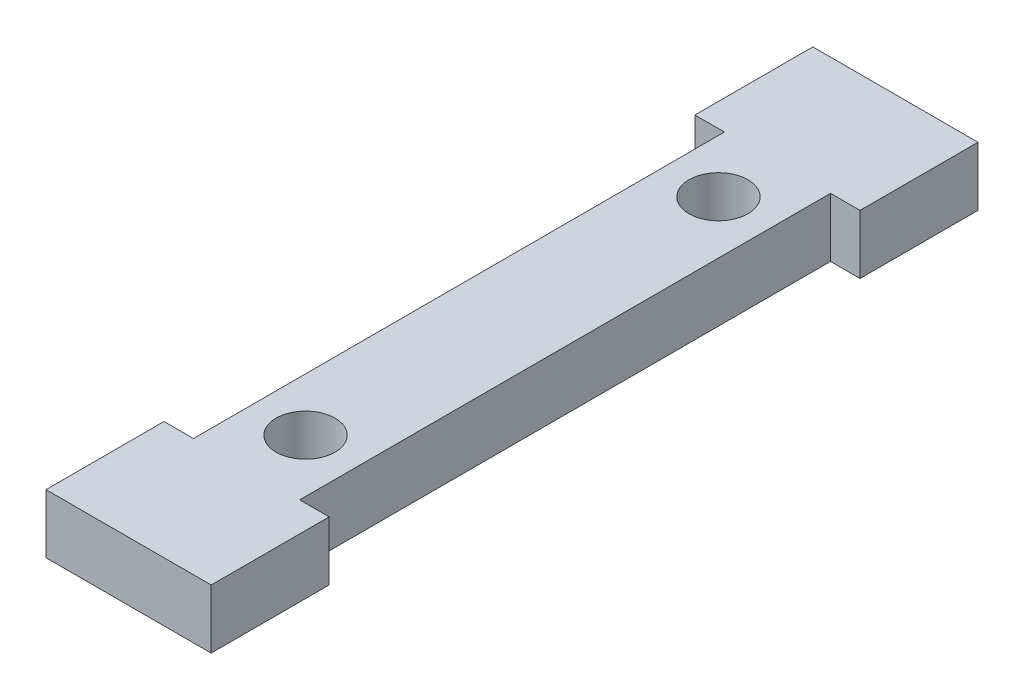
from build123d import *

# Parameters (mm, degrees)
SKETCH1_R           = 3.175
BOSS_EXTRUDE2_DEPTH = 6.35


with BuildPart() as part:
    # Sketch1 → Boss-Extrude2 (new body)
    with BuildSketch(Plane(origin=(0, 0, 0), x_dir=(1, 0, 0), z_dir=(0, 1, 0))):
        Polygon((-3.175, 0), (14.605, 0), (14.605, 12.7), (11.43, 12.7), (11.43, 69.85), (14.605, 69.85), (14.605, 82.55), (-3.175, 82.55), (-3.175, 69.85), (0, 69.85), (0, 12.7), (-3.175, 12.7), align=None)
        with Locations((5.715, 63.5)):
            Circle(SKETCH1_R, mode=Mode.SUBTRACT)
        with Locations((5.715, 19.05)):
            Circle(SKETCH1_R, mode=Mode.SUBTRACT)
    extrude(amount=BOSS_EXTRUDE2_DEPTH)


solid = part.part
